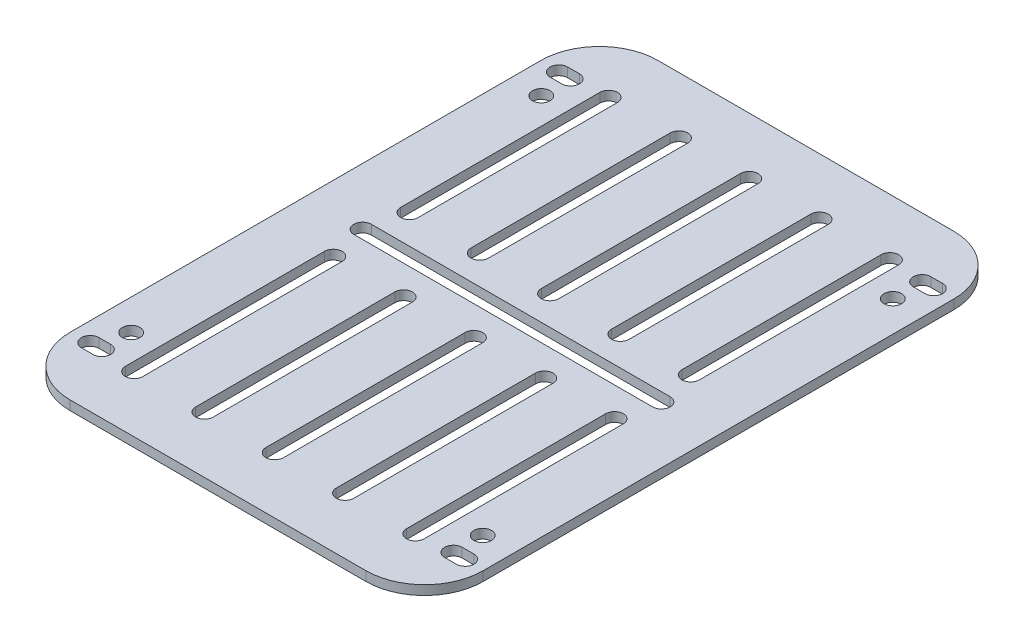
from build123d import *

# Parameters (mm, degrees)
SKETCH_1_W      = 70.5
SKETCH_1_H      = 100.35
SKETCH_1_R      = 1.5
EXTRUDE_1_DEPTH = 1.6
FILLET_1_R      = 10


with BuildPart() as part:
    # 草圖1 → 填料-伸長1 (new body)
    with BuildSketch(Plane(origin=(0, 0, 0), x_dir=(1, 0, 0), z_dir=(0, 1, 0))):
        Rectangle(SKETCH_1_W, SKETCH_1_H)
        with Locations((-30, 35)):
            Circle(SKETCH_1_R, mode=Mode.SUBTRACT)
        with Locations((30, 35)):
            Circle(SKETCH_1_R, mode=Mode.SUBTRACT)
        with Locations((-30, -35)):
            Circle(SKETCH_1_R, mode=Mode.SUBTRACT)
        with Locations((30, -35)):
            Circle(SKETCH_1_R, mode=Mode.SUBTRACT)
        with BuildLine():
            Line((-25.5, 1.5), (25.5, 1.5))
            ThreePointArc((25.5, 1.5), (27, 0), (25.5, -1.5))
            Line((25.5, -1.5), (-25.5, -1.5))
            ThreePointArc((-25.5, -1.5), (-27, 0), (-25.5, 1.5))
        make_face(mode=Mode.SUBTRACT)
        with BuildLine():
            Line((1.5, 40.5), (1.5, 6.5))
            ThreePointArc((1.5, 6.5), (0, 5), (-1.5, 6.5))
            Line((-1.5, 6.5), (-1.5, 40.5))
            ThreePointArc((-1.5, 40.5), (0, 42), (1.5, 40.5))
        make_face(mode=Mode.SUBTRACT)
        with BuildLine():
            Line((1.5, -40.5), (1.5, -6.5))
            ThreePointArc((1.5, -6.5), (0, -5), (-1.5, -6.5))
            Line((-1.5, -6.5), (-1.5, -40.5))
            ThreePointArc((-1.5, -40.5), (0, -42), (1.5, -40.5))
        make_face(mode=Mode.SUBTRACT)
        with BuildLine():
            Line((13.5, 40.5), (13.5, 6.5))
            ThreePointArc((13.5, 6.5), (12, 5), (10.5, 6.5))
            Line((10.5, 6.5), (10.5, 40.5))
            ThreePointArc((10.5, 40.5), (12, 42), (13.5, 40.5))
        make_face(mode=Mode.SUBTRACT)
        with BuildLine():
            Line((13.5, -40.5), (13.5, -6.5))
            ThreePointArc((13.5, -6.5), (12, -5), (10.5, -6.5))
            Line((10.5, -6.5), (10.5, -40.5))
            ThreePointArc((10.5, -40.5), (12, -42), (13.5, -40.5))
        make_face(mode=Mode.SUBTRACT)
        with BuildLine():
            Line((25.5, 40.5), (25.5, 6.5))
            ThreePointArc((25.5, 6.5), (24, 5), (22.5, 6.5))
            Line((22.5, 6.5), (22.5, 40.5))
            ThreePointArc((22.5, 40.5), (24, 42), (25.5, 40.5))
        make_face(mode=Mode.SUBTRACT)
        with BuildLine():
            Line((25.5, -40.5), (25.5, -6.5))
            ThreePointArc((25.5, -6.5), (24, -5), (22.5, -6.5))
            Line((22.5, -6.5), (22.5, -40.5))
            ThreePointArc((22.5, -40.5), (24, -42), (25.5, -40.5))
        make_face(mode=Mode.SUBTRACT)
        with BuildLine():
            Line((-25.5, -40.5), (-25.5, -6.5))
            ThreePointArc((-25.5, -6.5), (-24, -5), (-22.5, -6.5))
            Line((-22.5, -6.5), (-22.5, -40.5))
            ThreePointArc((-22.5, -40.5), (-24, -42), (-25.5, -40.5))
        make_face(mode=Mode.SUBTRACT)
        with BuildLine():
            Line((-13.5, -40.5), (-13.5, -6.5))
            ThreePointArc((-13.5, -6.5), (-12, -5), (-10.5, -6.5))
            Line((-10.5, -6.5), (-10.5, -40.5))
            ThreePointArc((-10.5, -40.5), (-12, -42), (-13.5, -40.5))
        make_face(mode=Mode.SUBTRACT)
        with BuildLine():
            Line((-13.5, 40.5), (-13.5, 6.5))
            ThreePointArc((-13.5, 6.5), (-12, 5), (-10.5, 6.5))
            Line((-10.5, 6.5), (-10.5, 40.5))
            ThreePointArc((-10.5, 40.5), (-12, 42), (-13.5, 40.5))
        make_face(mode=Mode.SUBTRACT)
        with BuildLine():
            Line((-25.5, 40.5), (-25.5, 6.5))
            ThreePointArc((-25.5, 6.5), (-24, 5), (-22.5, 6.5))
            Line((-22.5, 6.5), (-22.5, 40.5))
            ThreePointArc((-22.5, 40.5), (-24, 42), (-25.5, 40.5))
        make_face(mode=Mode.SUBTRACT)
        with BuildLine():
            Line((-32, 41.5), (-30, 41.5))
            ThreePointArc((-30, 41.5), (-28.5, 40), (-30, 38.5))
            Line((-30, 38.5), (-32, 38.5))
            ThreePointArc((-32, 38.5), (-33.5, 40), (-32, 41.5))
        make_face(mode=Mode.SUBTRACT)
        with BuildLine():
            Line((32, 41.5), (30, 41.5))
            ThreePointArc((30, 41.5), (28.5, 40), (30, 38.5))
            Line((30, 38.5), (32, 38.5))
            ThreePointArc((32, 38.5), (33.5, 40), (32, 41.5))
        make_face(mode=Mode.SUBTRACT)
        with BuildLine():
            Line((32, -41.5), (30, -41.5))
            ThreePointArc((30, -41.5), (28.5, -40), (30, -38.5))
            Line((30, -38.5), (32, -38.5))
            ThreePointArc((32, -38.5), (33.5, -40), (32, -41.5))
        make_face(mode=Mode.SUBTRACT)
        with BuildLine():
            Line((-32, -41.5), (-30, -41.5))
            ThreePointArc((-30, -41.5), (-28.5, -40), (-30, -38.5))
            Line((-30, -38.5), (-32, -38.5))
            ThreePointArc((-32, -38.5), (-33.5, -40), (-32, -41.5))
        make_face(mode=Mode.SUBTRACT)
    extrude(amount=EXTRUDE_1_DEPTH)

    # 圓角1
    fillet_1_edges = [part.edges().sort_by_distance(p)[0] for p in [
        (35.25, 0.8, 50.175),
        (-35.25, 0.8, 50.175),
        (-35.25, 0.8, -50.175),
        (35.25, 0.8, -50.175),
    ]]
    fillet(fillet_1_edges, radius=FILLET_1_R)


solid = part.part
